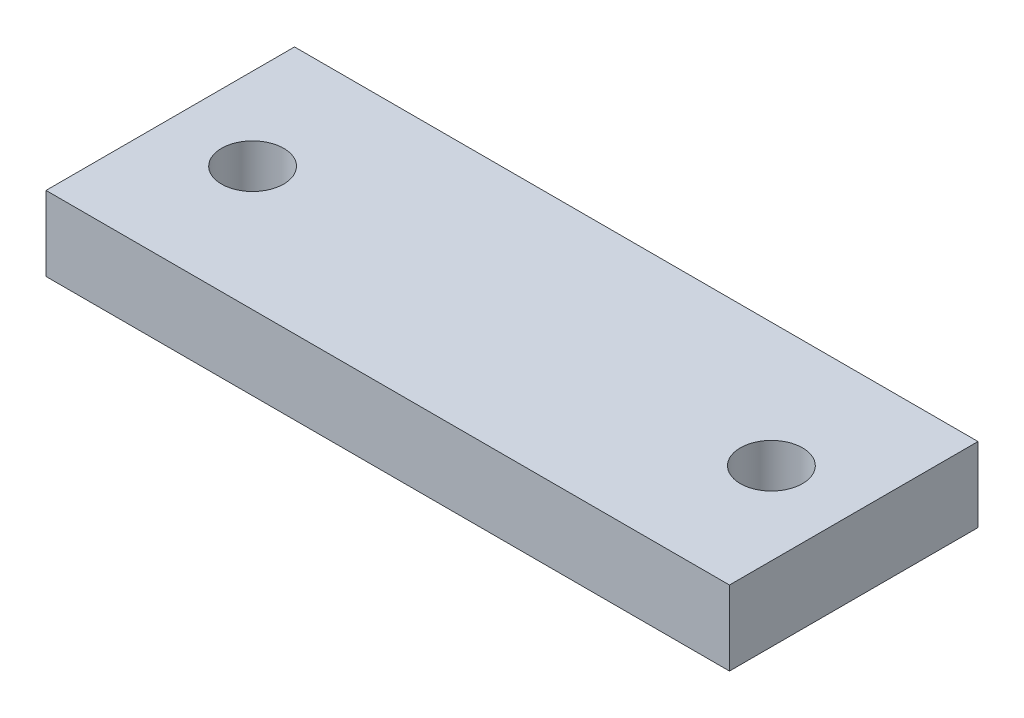
from build123d import *

# Parameters (mm, degrees)
SKETCH1_W           = 55
SKETCH1_H           = 20
BOSS_EXTRUDE1_DEPTH = 6
SKETCH2_R           = 2.5
CUT_EXTRUDE1_DEPTH  = 6


with BuildPart() as part:
    # Sketch1 → Boss-Extrude1 (new body)
    with BuildSketch(Plane(origin=(0, 0, 0), x_dir=(1, 0, 0), z_dir=(0, 1, 0))):
        Rectangle(SKETCH1_W, SKETCH1_H)
    extrude(amount=BOSS_EXTRUDE1_DEPTH)

    # Sketch2 → Cut-Extrude1 (cut)
    with BuildSketch(Plane(origin=(0, 6, 0), x_dir=(1, 0, 0), z_dir=(0, 1, 0))):
        with Locations((-20.875, 0)):
            Circle(SKETCH2_R)
        with Locations((20.875, 0)):
            Circle(SKETCH2_R)
    extrude(amount=-CUT_EXTRUDE1_DEPTH, mode=Mode.SUBTRACT)


solid = part.part
